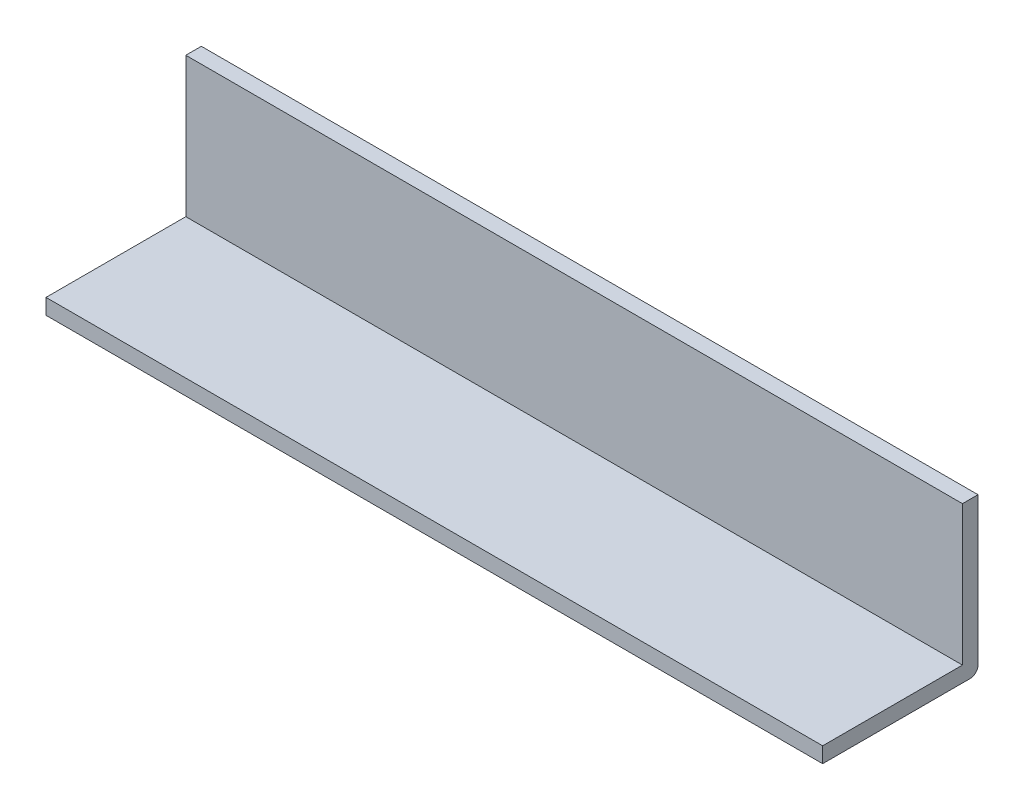
from build123d import *

# Parameters (mm, degrees)
SKETCH1_W           = 9
SKETCH1_H           = 1
SKETCH1_W_2         = 1
SKETCH1_H_2         = 9
BOSS_EXTRUDE1_DEPTH = 50


with BuildPart() as part:
    # Sketch1 → Boss-Extrude1 (new body)
    with BuildSketch(Plane(origin=(0, 0, 0), x_dir=(0, 0, -1), z_dir=(1, 0, 0))):
        with Locations((-15.137894846, 6.81112979)):
            Rectangle(SKETCH1_W, SKETCH1_H)
        with Locations((-10.137894846, 11.81112979)):
            Rectangle(SKETCH1_W_2, SKETCH1_H_2)
        with BuildLine():
            Line((-9.637894846, 7.31112979), (-10.637894846, 7.31112979))
            Line((-10.637894846, 7.31112979), (-10.637894846, 6.31112979))
            Line((-10.637894846, 6.31112979), (-10.137894846, 6.31112979))
            ThreePointArc((-10.137894846, 6.31112979), (-9.784341456, 6.4575764), (-9.637894846, 6.81112979))
            Line((-9.637894846, 6.81112979), (-9.637894846, 7.31112979))
        make_face()
    extrude(amount=BOSS_EXTRUDE1_DEPTH)


solid = part.part
